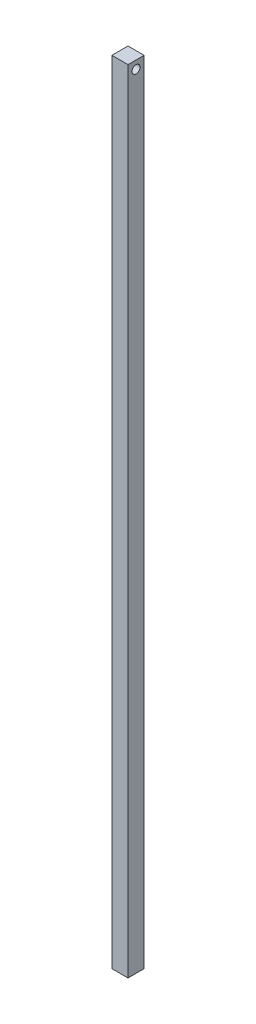
from build123d import *

# Parameters (mm, degrees)
SKETCH1_W           = 25.4
SKETCH1_H           = 25.4
BOSS_EXTRUDE1_DEPTH = 1244.6
SKETCH2_R           = 6.35
CUT_EXTRUDE1_DEPTH  = 25.4


with BuildPart() as part:
    # Sketch1 → Boss-Extrude1 (new body)
    with BuildSketch(Plane(origin=(0, 0, 0), x_dir=(1, 0, 0), z_dir=(0, 1, 0))):
        with Locations((4.003864344, -5.496691195)):
            Rectangle(SKETCH1_W, SKETCH1_H)
    extrude(amount=BOSS_EXTRUDE1_DEPTH)

    # Sketch2 → Cut-Extrude1 (cut)
    with BuildSketch(Plane.ZY.offset(8.696135656)):
        with Locations((5.496691195, 1231.9)):
            Circle(SKETCH2_R)
    extrude(amount=-CUT_EXTRUDE1_DEPTH, mode=Mode.SUBTRACT)


solid = part.part
